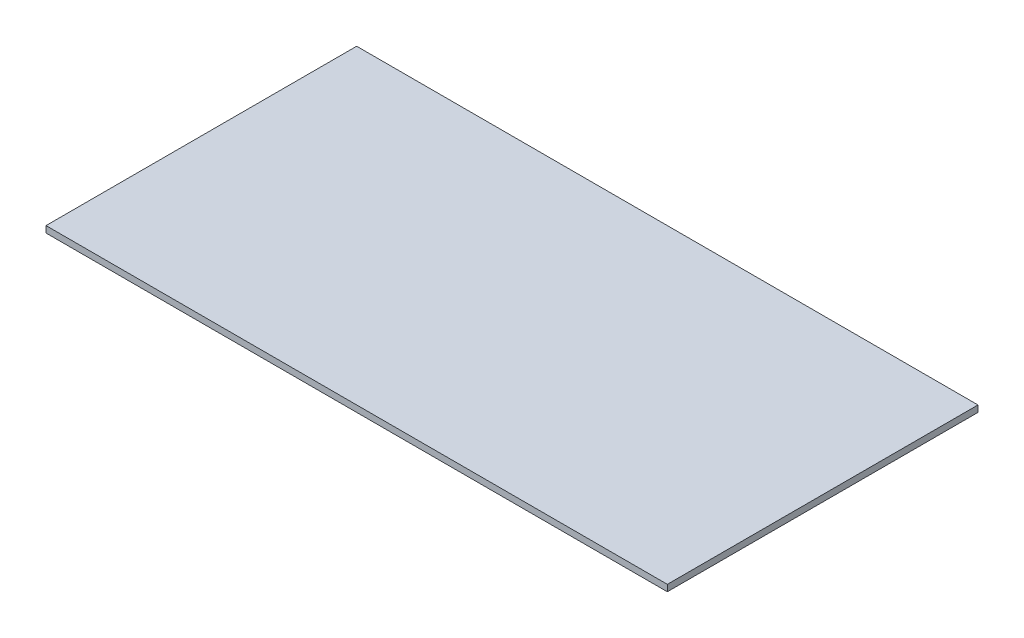
from build123d import *

# Parameters (mm, degrees)
SKETCH1_W           = 1219.2
SKETCH1_H           = 609.6
BOSS_EXTRUDE1_DEPTH = 12.7


with BuildPart() as part:
    # Sketch1 → Boss-Extrude1 (new body)
    with BuildSketch(Plane(origin=(0, 0, 0), x_dir=(1, 0, 0), z_dir=(0, 1, 0))):
        with Locations((609.6, 304.8)):
            Rectangle(SKETCH1_W, SKETCH1_H)
    extrude(amount=BOSS_EXTRUDE1_DEPTH)


solid = part.part
